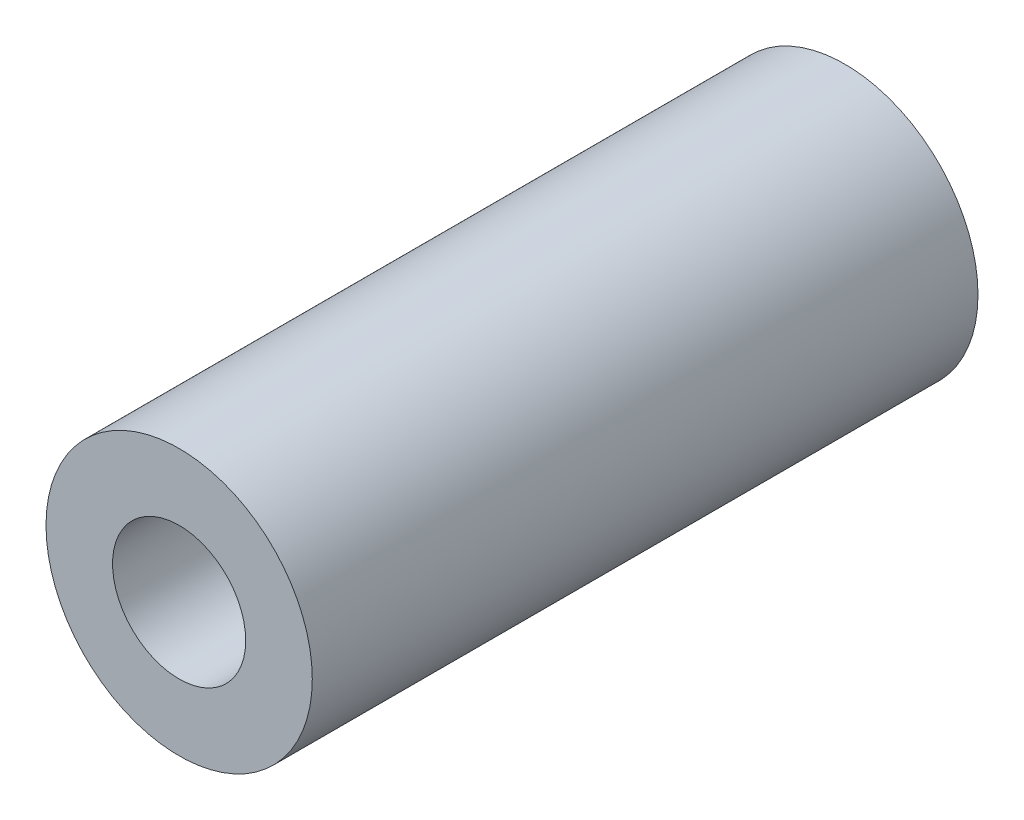
from build123d import *

# Parameters (mm, degrees)
SKETCH1_R                     = 2
SKETCH1_R_2                   = 1
BOSS_EXTRUDE1_DEPTH           = 10
SKETCH2_R                     = 1.28905
HOLE_FOR_5_40_SET_SCREW_DEPTH = 3


with BuildPart() as part:
    # Sketch1 → Boss-Extrude1 (new body)
    with BuildSketch(Plane.XY):
        Circle(SKETCH1_R)
        Circle(SKETCH1_R_2, mode=Mode.SUBTRACT)
    extrude(amount=BOSS_EXTRUDE1_DEPTH)

    # Sketch2 → hole for 5-40 set screw (cut, through all)
    with BuildSketch(Plane(origin=(0, 0, 0), x_dir=(0, 0, -1), z_dir=(1, 0, 0))):
        with Locations((-4, 0)):
            Circle(SKETCH2_R)
    extrude(amount=-HOLE_FOR_5_40_SET_SCREW_DEPTH, mode=Mode.SUBTRACT)


solid = part.part
